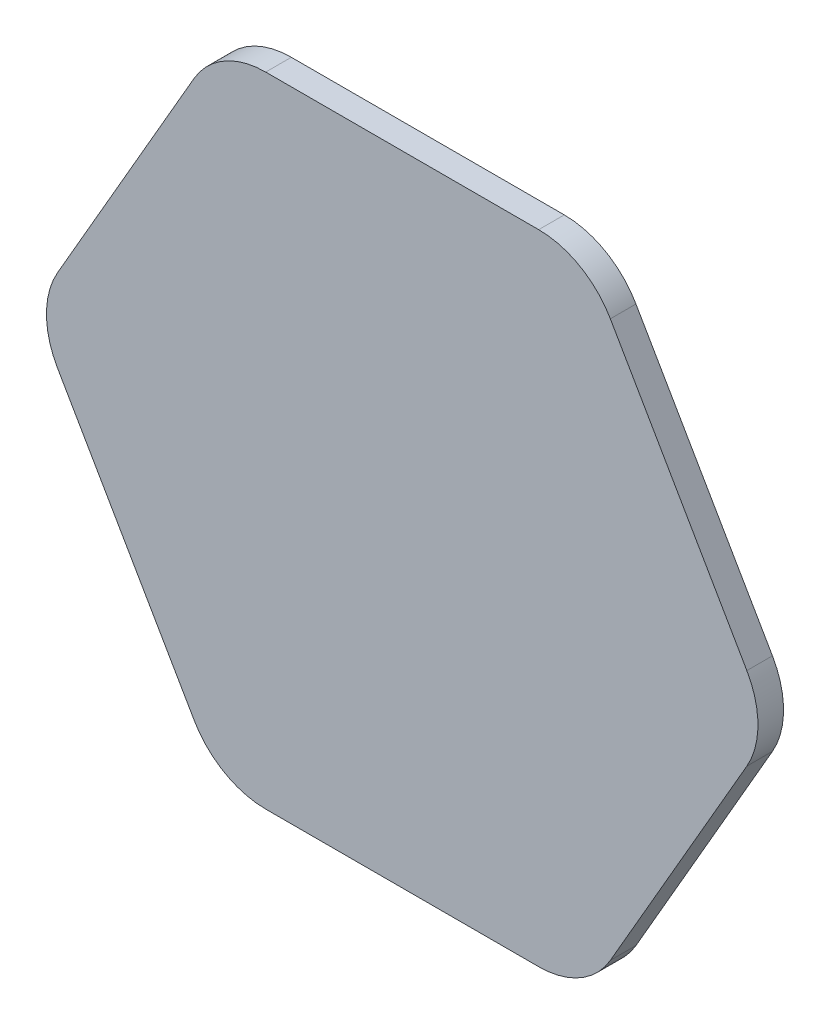
from build123d import *

# Parameters (mm, degrees)
BOSS_EXTRUDE1_DEPTH = 4.7625


with BuildPart() as part:
    # Sketch2 → Boss-Extrude1 (new body)
    with BuildSketch(Plane.XY):
        with BuildLine():
            Line((64.13459107, 7.698729744), (38.73459107, 51.692820256))
            ThreePointArc((38.73459107, 51.692820256), (33.098729744, 57.328681582), (25.4, 59.39155))
            Line((25.4, 59.39155), (-25.4, 59.39155))
            ThreePointArc((-25.4, 59.39155), (-33.098729744, 57.328681582), (-38.73459107, 51.692820256))
            Line((-38.73459107, 51.692820256), (-64.13459107, 7.698729744))
            ThreePointArc((-64.13459107, 7.698729744), (-66.197459488, 0), (-64.13459107, -7.698729744))
            Line((-64.13459107, -7.698729744), (-38.73459107, -51.692820256))
            ThreePointArc((-38.73459107, -51.692820256), (-33.098729744, -57.328681582), (-25.4, -59.39155))
            Line((-25.4, -59.39155), (25.4, -59.39155))
            ThreePointArc((25.4, -59.39155), (33.098729744, -57.328681582), (38.73459107, -51.692820256))
            Line((38.73459107, -51.692820256), (64.13459107, -7.698729744))
            ThreePointArc((64.13459107, -7.698729744), (66.197459488, 0), (64.13459107, 7.698729744))
        make_face()
    extrude(amount=BOSS_EXTRUDE1_DEPTH)


solid = part.part
